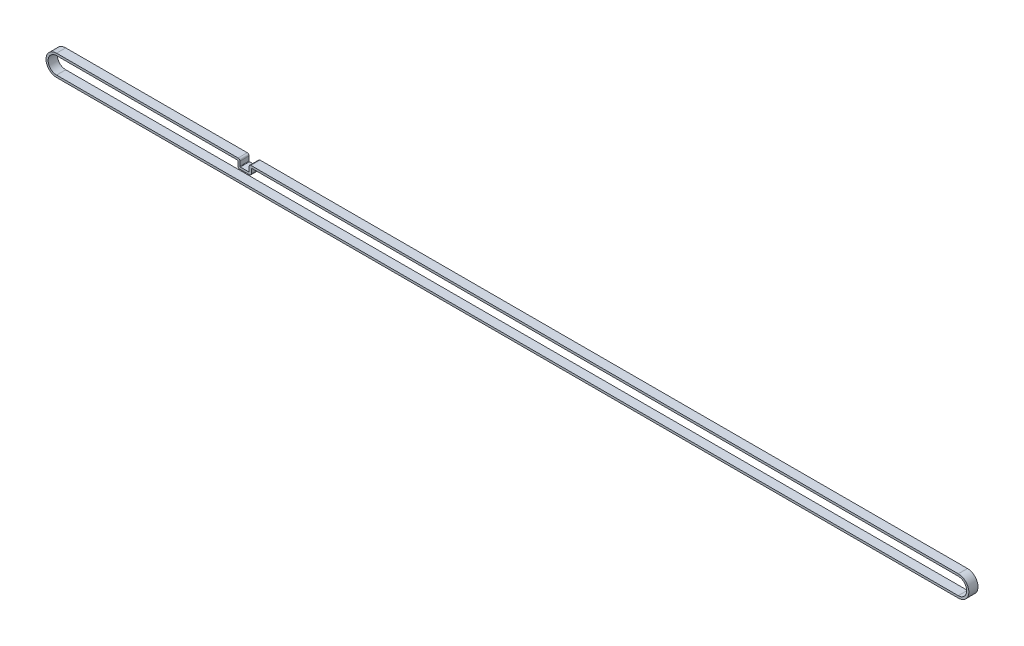
from build123d import *

# Parameters (mm, degrees)
SALIENTE_EXTRUIR1_DEPTH = 6
REDONDEO1_R             = 0.3
REDONDEO2_R             = 1.2


with BuildPart() as part:
    # Croquis1 → Saliente-Extruir1 (new body)
    with BuildSketch(Plane.XY):
        with BuildLine():
            Line((0, 6.9), (120, 6.9))
            Line((120, 6.9), (120, 2.5))
            Line((120, 2.5), (126, 2.5))
            Line((126, 2.5), (126, 6.9))
            Line((126, 6.9), (590, 6.9))
            ThreePointArc((590, 6.9), (596.9, 0), (590, -6.9))
            Line((590, -6.9), (0, -6.9))
            ThreePointArc((0, -6.9), (-6.9, 0), (0, 6.9))
        make_face()
        with BuildLine():
            Line((0, 5.5), (118.6, 5.5))
            Line((118.6, 5.5), (118.6, 1.1))
            Line((118.6, 1.1), (127.4, 1.1))
            Line((127.4, 1.1), (127.4, 5.5))
            Line((127.4, 5.5), (590, 5.5))
            ThreePointArc((590, 5.5), (595.5, 0), (590, -5.5))
            Line((590, -5.5), (0, -5.5))
            ThreePointArc((0, -5.5), (-5.5, 0), (0, 5.5))
        make_face(mode=Mode.SUBTRACT)
    extrude(amount=SALIENTE_EXTRUIR1_DEPTH)

    # Redondeo1
    redondeo1_edges = [part.edges().sort_by_distance(p)[0] for p in [
        (120, 2.5, 3),
        (126, 2.5, 3),
        (127.4, 5.5, 3),
        (118.6, 5.5, 3),
    ]]
    fillet(redondeo1_edges, radius=REDONDEO1_R)

    # Redondeo2
    redondeo2_edges = [part.edges().sort_by_distance(p)[0] for p in [
        (120, 6.9, 3),
        (126, 6.9, 3),
        (127.4, 1.1, 3),
        (118.6, 1.1, 3),
    ]]
    fillet(redondeo2_edges, radius=REDONDEO2_R)


solid = part.part
